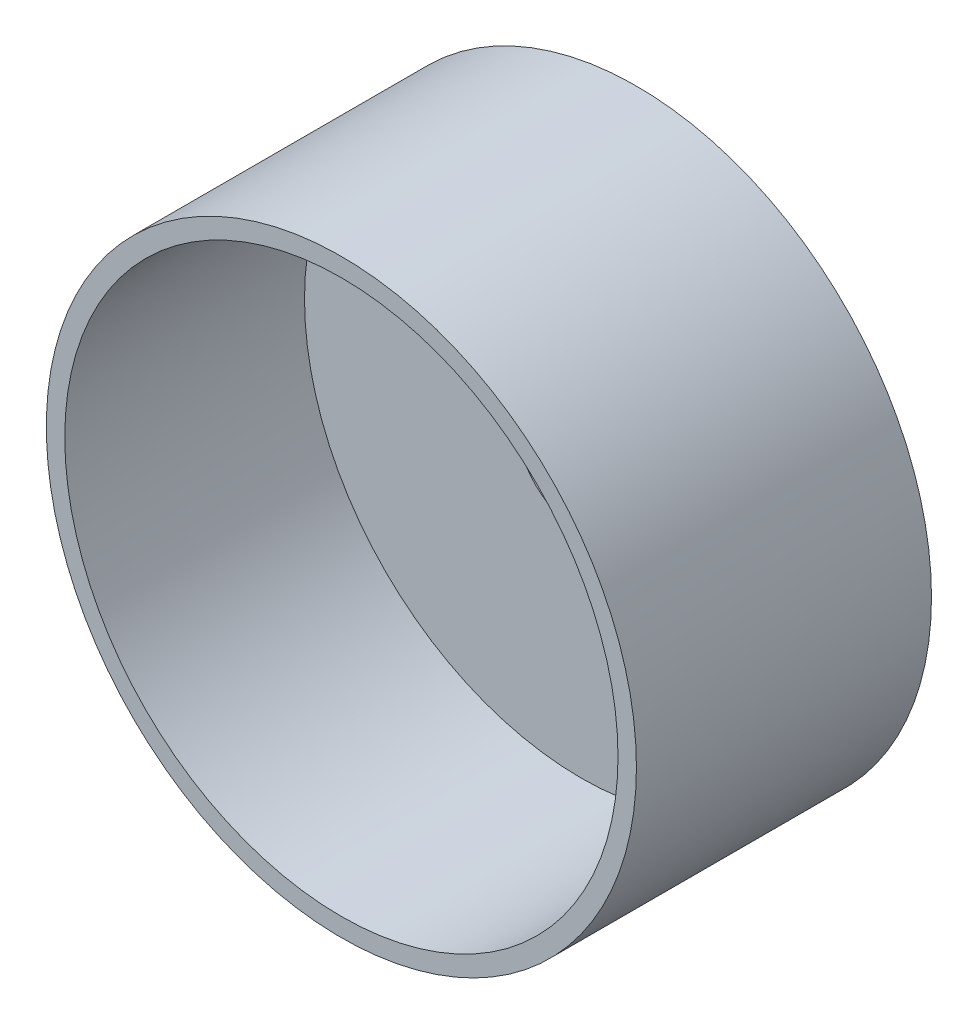
from build123d import *


with BuildPart() as part:
    # Sketch1 → Revolve1 (revolve)
    with BuildSketch(Plane(origin=(0, 0, 0), x_dir=(1, 0, 0), z_dir=(0, 1, 0))):
        Polygon((44.45, 0), (44.45, 44.45), (152.4, 44.45), (152.4, 38.1), (203.2, 38.1), (203.2, -165.1), (190.5, -165.1), (190.5, 0), align=None)
    revolve(axis=Axis((0, 0, 0), (0, 0, -1)))


solid = part.part
